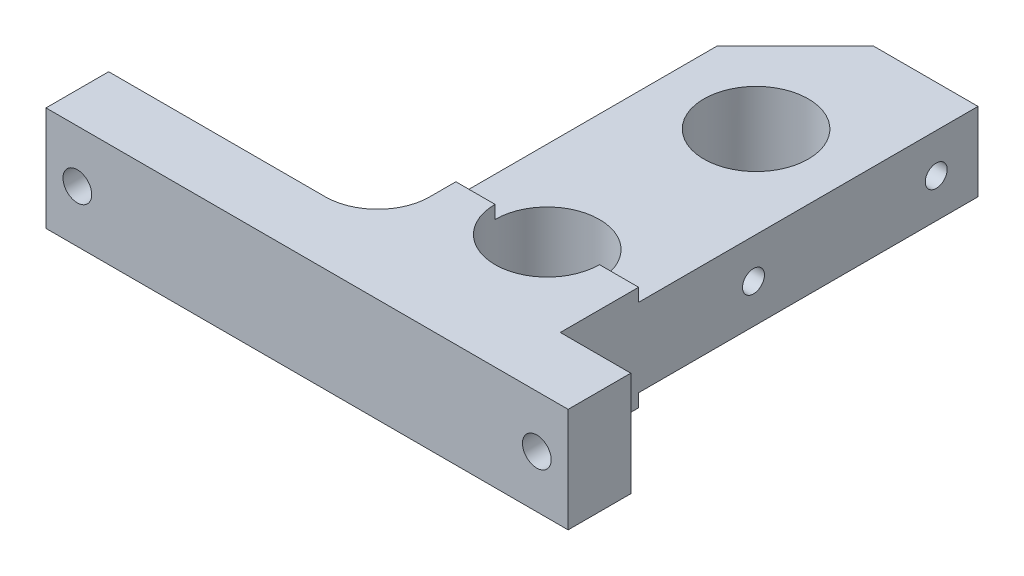
from build123d import *

# Parameters (mm, degrees)
SKETCH1_W               = 100
SKETCH1_H               = 20
BOSS_EXTRUDE1_DEPTH     = 12
SKETCH2_W               = 35
SKETCH2_H               = 20
BOSS_EXTRUDE3_DEPTH     = 15
SKETCH3_W               = 35
SKETCH3_H               = 15
BOSS_EXTRUDE4_DEPTH     = 65
FILLET1_R               = 10
CHAMFER1_SIZE           = 15
SKETCH4_R               = 10
CUT_EXTRUDE1_DEPTH      = 65
CUT_EXTRUDE1_DEPTH_BACK = 65
M5_TAPPED_HOLE1_D       = 4.2
M5_TAPPED_HOLE1_DEPTH   = 10
M5_TAPPED_HOLE1_TIP     = 1.2618073
SKETCH7_R               = 2.75
CUT_EXTRUDE2_DEPTH      = 65


with BuildPart() as part:
    # Sketch1 → Boss-Extrude1 (new body)
    with BuildSketch(Plane.XY):
        Rectangle(SKETCH1_W, SKETCH1_H)
    extrude(amount=BOSS_EXTRUDE1_DEPTH)

    # Sketch2 → Boss-Extrude3 (add)
    with BuildSketch(Plane(origin=(0, 0, 0), x_dir=(-1, 0, 0), z_dir=(0, 0, -1))):
        with Locations((-19, 0)):
            Rectangle(SKETCH2_W, SKETCH2_H)
    extrude(amount=BOSS_EXTRUDE3_DEPTH)

    # Sketch3 → Boss-Extrude4 (add)
    with BuildSketch(Plane(origin=(0, 0, -15), x_dir=(-1, 0, 0), z_dir=(0, 0, -1))):
        with Locations((-19, 0)):
            Rectangle(SKETCH3_W, SKETCH3_H)
    extrude(amount=BOSS_EXTRUDE4_DEPTH)

    # Fillet1
    fillet1_edges = [part.edges().sort_by_distance(p)[0] for p in [
        (1.5, 0, 0),
    ]]
    fillet(fillet1_edges, radius=FILLET1_R)

    # Chamfer1
    chamfer1_edges = [part.edges().sort_by_distance(p)[0] for p in [
        (1.5, 0, -80),
    ]]
    chamfer(chamfer1_edges, length=CHAMFER1_SIZE)

    # Sketch4 → Cut-Extrude1 (cut, two sides)
    with BuildSketch(Plane(origin=(0, 7.5, 0), x_dir=(1, 0, 0), z_dir=(0, 1, 0))) as cut_extrude1_sk:
        with Locations((19, 15)):
            Circle(SKETCH4_R)
        with Locations((19, 55)):
            Circle(SKETCH4_R)
    extrude(amount=CUT_EXTRUDE1_DEPTH, mode=Mode.SUBTRACT)
    extrude(cut_extrude1_sk.sketch, amount=-CUT_EXTRUDE1_DEPTH_BACK, mode=Mode.SUBTRACT)

    # M5 Tapped Hole1
    with Locations(Plane(origin=(36.5, 0, 0), x_dir=(0, 0, -1), z_dir=(1, 0, 0))):
        with Locations((72, 0), (37, 0)):
            Hole(M5_TAPPED_HOLE1_D / 2, depth=M5_TAPPED_HOLE1_DEPTH)
            with Locations((0, 0, -(M5_TAPPED_HOLE1_DEPTH + M5_TAPPED_HOLE1_TIP / 2))):  # 118° drill point
                Cone(0, M5_TAPPED_HOLE1_D / 2, M5_TAPPED_HOLE1_TIP, mode=Mode.SUBTRACT)

    # Sketch7 → Cut-Extrude2 (cut)
    with BuildSketch(Plane(origin=(0, 0, 0), x_dir=(-1, 0, 0), z_dir=(0, 0, -1))):
        with Locations((44, 0)):
            Circle(SKETCH7_R)
        with Locations((-44, 0)):
            Circle(SKETCH7_R)
    extrude(amount=-CUT_EXTRUDE2_DEPTH, mode=Mode.SUBTRACT)


solid = part.part
